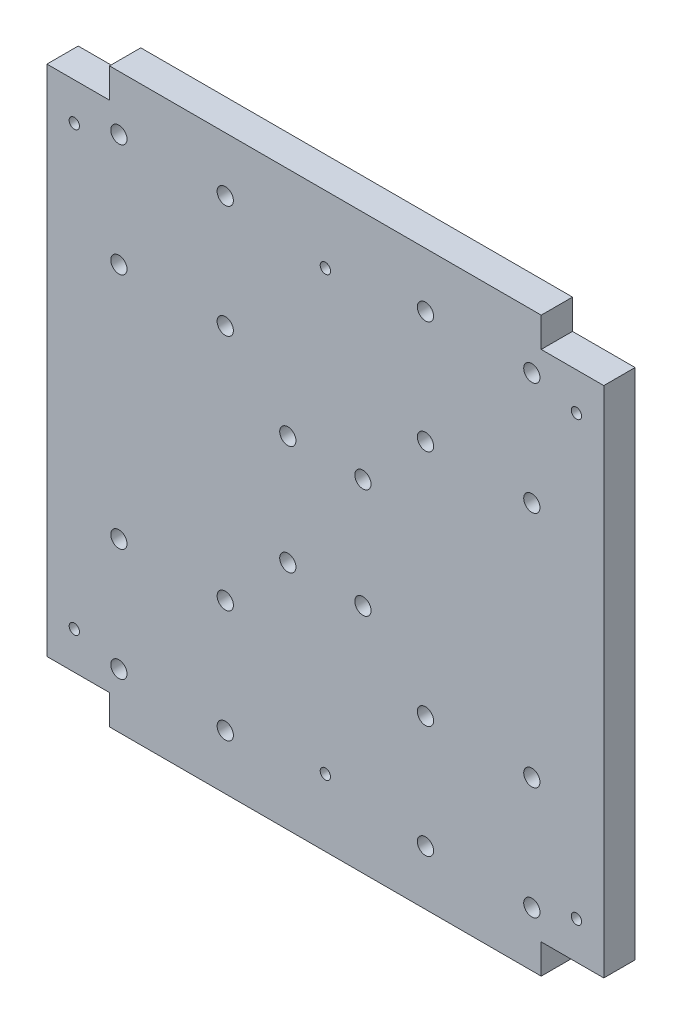
from build123d import *

# Parameters (mm, degrees)
SKETCH1_R           = 2.6
BOSS_EXTRUDE3_DEPTH = 10
M4_TAPPED_HOLE1_D   = 3.3


with BuildPart() as part:
    # Sketch1 → Boss-Extrude3 (new body)
    with BuildSketch(Plane.XY):
        Polygon((-89, 82), (-89, -82), (-69, -82), (-69, -91.5), (69, -91.5), (69, -82), (89, -82), (89, 82), (69, 82), (69, 91.5), (-69, 91.5), (-69, 82), align=None)
        with Locations((-66, 74)):
            Circle(SKETCH1_R, mode=Mode.SUBTRACT)
        with Locations((-32, 74)):
            Circle(SKETCH1_R, mode=Mode.SUBTRACT)
        with Locations((-32, 38)):
            Circle(SKETCH1_R, mode=Mode.SUBTRACT)
        with Locations((-66, 38)):
            Circle(SKETCH1_R, mode=Mode.SUBTRACT)
        with Locations((66, 38)):
            Circle(SKETCH1_R, mode=Mode.SUBTRACT)
        with Locations((32, 38)):
            Circle(SKETCH1_R, mode=Mode.SUBTRACT)
        with Locations((32, 74)):
            Circle(SKETCH1_R, mode=Mode.SUBTRACT)
        with Locations((66, 74)):
            Circle(SKETCH1_R, mode=Mode.SUBTRACT)
        with Locations((66, -74)):
            Circle(SKETCH1_R, mode=Mode.SUBTRACT)
        with Locations((32, -74)):
            Circle(SKETCH1_R, mode=Mode.SUBTRACT)
        with Locations((32, -38)):
            Circle(SKETCH1_R, mode=Mode.SUBTRACT)
        with Locations((66, -38)):
            Circle(SKETCH1_R, mode=Mode.SUBTRACT)
        with Locations((-66, -38)):
            Circle(SKETCH1_R, mode=Mode.SUBTRACT)
        with Locations((-32, -38)):
            Circle(SKETCH1_R, mode=Mode.SUBTRACT)
        with Locations((-32, -74)):
            Circle(SKETCH1_R, mode=Mode.SUBTRACT)
        with Locations((-66, -74)):
            Circle(SKETCH1_R, mode=Mode.SUBTRACT)
        with Locations((-12, 17.5)):
            Circle(SKETCH1_R, mode=Mode.SUBTRACT)
        with Locations((12, 17.5)):
            Circle(SKETCH1_R, mode=Mode.SUBTRACT)
        with Locations((12, -17.5)):
            Circle(SKETCH1_R, mode=Mode.SUBTRACT)
        with Locations((-12, -17.5)):
            Circle(SKETCH1_R, mode=Mode.SUBTRACT)
    extrude(amount=BOSS_EXTRUDE3_DEPTH)

    # M4 Tapped Hole1 (through all)
    with Locations(Plane.XY.offset(10)):
        with Locations((-80.25, 70), (80.25, 70), (0, 70), (0, -70), (80.25, -70), (-80.25, -70)):
            Hole(M4_TAPPED_HOLE1_D / 2)


solid = part.part
